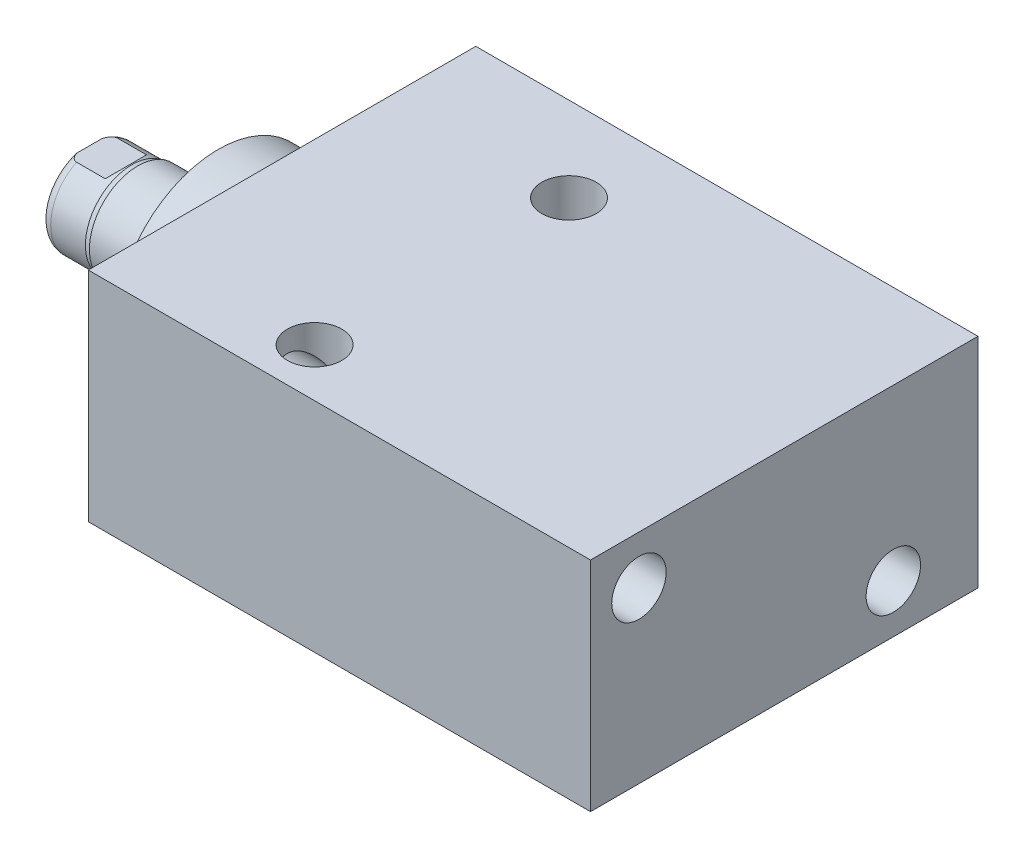
from build123d import *

# Parameters (mm, degrees)
SKETCH1_W          = 50.8
SKETCH1_H          = 28.575
EXTRUDE1_DEPTH     = 65.8368
LPATTERN1_COUNT    = 2
LPATTERN1_PITCH    = 46.99
SKETCH5_R          = 13.5001
EXTRUDE2_DEPTH     = 5.969
SKETCH6_W          = 6.3373
SKETCH6_H          = 16.891
CUT_EXTRUDE4_DEPTH = 30.48
HOLE1_D            = 7.137
HOLE1_DEPTH        = 65.8368
HOLE2_D            = 7.137
HOLE2_DEPTH        = 28.575


with BuildPart() as part:
    # Sketch1 → Extrude1 (new body)
    with BuildSketch(Plane(origin=(0, 0, 0), x_dir=(0, 0, -1), z_dir=(1, 0, 0))):
        with Locations((2.3876, 0)):
            Rectangle(SKETCH1_W, SKETCH1_H)
    extrude(amount=EXTRUDE1_DEPTH)

    # S2D0002 → Cut-Revolve1 (revolve, cut)
    with BuildSketch(Plane(origin=(0, 4.7625, 0), x_dir=(-1, 0, 0), z_dir=(0, 1, 0)), mode=Mode.PRIVATE) as cut_revolve1_sk:
        Polygon((-14.5415, -27.5336), (-18.161, -27.5336), (-18.161, -27.7876), (-9.525, -27.7876), (-9.525, -14.0716), (-13.9446, -14.0716), (-13.9446, -26.9113), (-14.5415, -27.5082), align=None)
    cut_revolve1 = revolve(cut_revolve1_sk.sketch.rotate(Axis((9.525, 4.7625, -19.13842003), (0, 0, 1)), 180), axis=Axis((9.525, 4.7625, -19.13842003), (0, 0, 1)), mode=Mode.SUBTRACT)  # turned: the seam where the file's is

    # LPattern1: Cut-Revolve1 ×2
    with Locations(*[(i * LPATTERN1_PITCH, 0, 0) for i in range(1, LPATTERN1_COUNT)]):
        add(cut_revolve1, mode=Mode.SUBTRACT)

    # Sketch5 → Extrude2 (add)
    with BuildSketch(Plane.ZY):
        Circle(SKETCH5_R)
    extrude(amount=EXTRUDE2_DEPTH)

    # Sketch6 → Revolve1 (revolve)
    with BuildSketch(Plane(origin=(0, 0, 0), x_dir=(0, 0, 1), z_dir=(0, -1, 0)), mode=Mode.PRIVATE) as revolve1_sk:
        with Locations((-3.16865, 14.4145)):
            Rectangle(SKETCH6_W, SKETCH6_H)
    revolve(revolve1_sk.sketch.rotate(Axis((5.754582971, 0, 0), (-1, 0, 0)), 180), axis=Axis((5.754582971, 0, 0), (-1, 0, 0)))  # turned: the seam where the file's is

    # S2D0001 → Cut-Revolve4 (revolve, cut)
    with BuildSketch(Plane(origin=(-18.511260017, 3.2639, 0), x_dir=(0, 1, 0), z_dir=(0, 0, 1)), mode=Mode.PRIVATE) as cut_revolve4_sk:
        Polygon((-0.7493, 2.984923177), (-0.7493, -11.653260017), (-3.2639, -13.16418413), (-3.2639, 4.348739983), (0.0381, 4.348739983), align=None)
    revolve(cut_revolve4_sk.sketch.rotate(Axis((0, 0, 0), (-1, 0, 0)), 90), axis=Axis((0, 0, 0), (-1, 0, 0)), mode=Mode.SUBTRACT)  # turned: the seam where the file's is

    # Sketch8 → Cut-Revolve5 (revolve, cut)
    with BuildSketch(Plane(origin=(0, 0, 0), x_dir=(0, 0, -1), z_dir=(0, 1, 0)), mode=Mode.PRIVATE) as cut_revolve5_sk:
        with BuildLine():
            Line((-6.3373, 16.5354), (-6.096, 17.2974))
            Line((-6.096, 17.2974), (-6.096, 21.844))
            ThreePointArc((-6.096, 21.844), (-5.995678675, 22.387796865), (-5.707922533, 22.86))
            Line((-5.707922533, 22.86), (-6.3373, 22.86))
            Line((-6.3373, 22.86), (-6.3373, 16.5354))
        make_face()
    revolve(cut_revolve5_sk.sketch.rotate(Axis((-12.65936, 0, 0), (-1, 0, 0)), 180), axis=Axis((-12.65936, 0, 0), (-1, 0, 0)), mode=Mode.SUBTRACT)  # turned: the seam where the file's is

    # Sketch12 → Cut-Extrude4 (cut, symmetric)
    with BuildSketch(Plane(origin=(0, 0, 0), x_dir=(0, -1, 0), z_dir=(0, 0, -1))):
        Polygon((5.461, 22.86), (5.461, 18.0848), (6.096, 17.4498), (6.096, 22.86), align=None)
        Polygon((-5.461, 22.86), (-5.461, 18.0848), (-6.096, 17.4498), (-6.096, 22.86), align=None)
    extrude(amount=CUT_EXTRUDE4_DEPTH, both=True, mode=Mode.SUBTRACT)

    # Hole1
    with Locations(Plane.ZY):
        with Locations((-16.6878, -7.9248), (16.6624, 7.9502)):
            Hole(HOLE1_D / 2, depth=HOLE1_DEPTH)

    # Hole2
    with Locations(Plane(origin=(0, 14.2875, 0), x_dir=(-1, 0, 0), z_dir=(0, 1, 0))):
        with Locations((-23.3172, -16.6878), (-23.3172, 16.6624)):
            Hole(HOLE2_D / 2, depth=HOLE2_DEPTH)


solid = part.part
